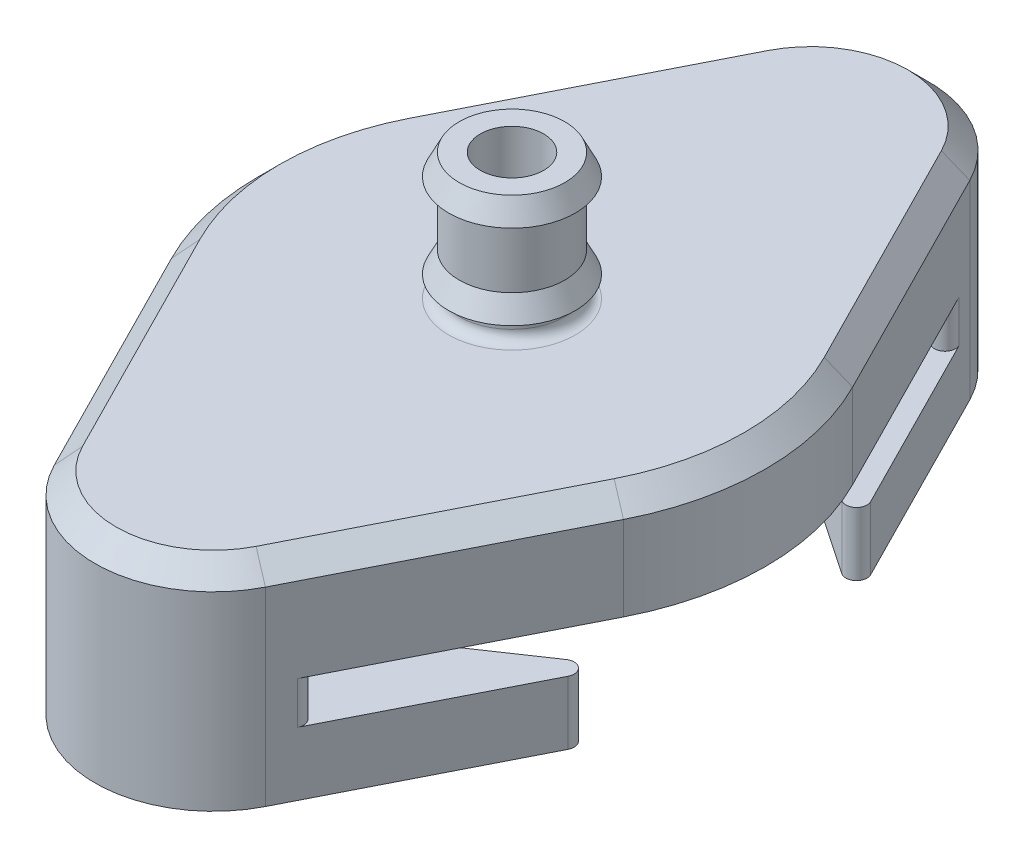
from build123d import *

# Parameters (mm, degrees)
CUT_EXTRUDE1_DEPTH = 11
CUT_EXTRUDE3_DEPTH = 5
FILLET1_R          = 0.5
FILLET3_R          = 0.5
CHAMFER2_SIZE      = 1
SKETCH12_R         = 1.4
CUT_EXTRUDE7_DEPTH = 5


with BuildPart() as part:
    # Sketch2 → Revolve1 (revolve)
    with BuildSketch(Plane(origin=(0, 0, 0), x_dir=(0, 0, -1), z_dir=(1, 0, 0))):
        Polygon((-2.5, 0), (-19.75, 0), (-19.75, -10), (-8.75, -10), (-8.75, -7), (-15.75, -7), (-15.75, -5), (-1.5, -5), (-1.5, 6), (-2.5, 6), (-3, 5), (-2.5, 5), (-2.5, 2), (-3, 1), (-2.5, 1), align=None)
    revolve(axis=Axis((0, 7.880012575, 0), (0, -1, 0)))

    # Sketch3 → Cut-Extrude1 (cut, through all)
    with BuildSketch(Plane(origin=(0, 0, 0), x_dir=(1, 0, 0), z_dir=(0, 1, 0))):
        with BuildLine():
            ThreePointArc((-10.703712775, -5.424991506), (-12, 0), (-10.703712775, 5.424991506))
            Line((-10.703712775, 5.424991506), (-5, 16.678631853))
            ThreePointArc((-5, 16.678631853), (-2.933994828, 18.920833005), (-3.1e-08, 19.75))
            ThreePointArc((-3.1e-08, 19.75), (-19.75, -1.6e-08), (0, -19.75))
            ThreePointArc((0, -19.75), (-2.933994815, -18.920833013), (-5, -16.678631853))
            Line((-5, -16.678631853), (-10.703712775, -5.424991506))
        make_face()
        with BuildLine():
            ThreePointArc((19.75, 0), (13.965358917, 13.965358939), (-3.1e-08, 19.75))
            ThreePointArc((-3.1e-08, 19.75), (2.933994802, 18.920833021), (5, 16.678631853))
            Line((5, 16.678631853), (10.703712775, 5.424991506))
            ThreePointArc((10.703712775, 5.424991506), (12, 0), (10.703712775, -5.424991506))
            Line((10.703712775, -5.424991506), (5, -16.678631853))
            ThreePointArc((5, -16.678631853), (2.933994815, -18.920833013), (0, -19.75))
            ThreePointArc((0, -19.75), (13.965358928, -13.965358928), (19.75, 0))
        make_face()
    extrude(amount=-CUT_EXTRUDE1_DEPTH, mode=Mode.SUBTRACT)

    # Sketch5 → Cut-Extrude3 (cut)
    with BuildSketch(Plane.XZ.offset(10)):
        with BuildLine():
            Line((-5.884741508, -8.695965581), (-11.34632201, -5))
            ThreePointArc((-11.34632201, -5), (-14, 0), (-11.34632201, 5))
            Line((-11.34632201, 5), (-5.884741508, 8.695965581))
            ThreePointArc((-5.884741508, 8.695965581), (0, 10.5), (5.884741508, 8.695965581))
            Line((5.884741508, 8.695965581), (11.34632201, 5))
            ThreePointArc((11.34632201, 5), (14, 0), (11.34632201, -5))
            Line((11.34632201, -5), (5.884741508, -8.695965581))
            ThreePointArc((5.884741508, -8.695965581), (0, -10.5), (-5.884741508, -8.695965581))
        make_face()
    extrude(amount=-CUT_EXTRUDE3_DEPTH, mode=Mode.SUBTRACT)

    # Fillet1
    fillet1_edges = [part.edges().sort_by_distance(p)[0] for p in [
        (-6.091971401, -6, -14.524131108),
        (-6.091971401, -6, 14.524131108),
        (6.091971401, -6, -14.524131108),
        (6.091971401, -6, 14.524131108),
        (10.696094588, -8.5, -5.440022476),
        (10.696094588, -8.5, 5.440022476),
        (-10.696094588, -8.5, 5.440022476),
        (-10.696094588, -8.5, -5.440022476),
    ]]
    fillet(fillet1_edges, radius=FILLET1_R)

    # Fillet3
    fillet3_edges = [part.edges().sort_by_distance(p)[0] for p in [
        (0, 0, -2.5),
    ]]
    fillet(fillet3_edges, radius=FILLET3_R)

    # Chamfer2
    chamfer2_edges = [part.edges().sort_by_distance(p)[0] for p in [
        (0, 0, 19.75),
        (-7.851856387, 0, 11.051811679),
        (-12, 0, 0),
        (-7.851856387, 0, -11.051811679),
        (0, 0, -19.75),
        (7.851856387, 0, 11.051811679),
        (7.851856387, 0, -11.051811679),
        (12, 0, 0),
    ]]
    chamfer(chamfer2_edges, length=CHAMFER2_SIZE)

    # Sketch12 → Cut-Extrude7 (cut)
    with BuildSketch(Plane.XZ.offset(10)):
        with Locations((0, -13.25)):
            Circle(SKETCH12_R)
        with Locations((0, 13.25)):
            Circle(SKETCH12_R)
    extrude(amount=-CUT_EXTRUDE7_DEPTH, mode=Mode.SUBTRACT)


solid = part.part
